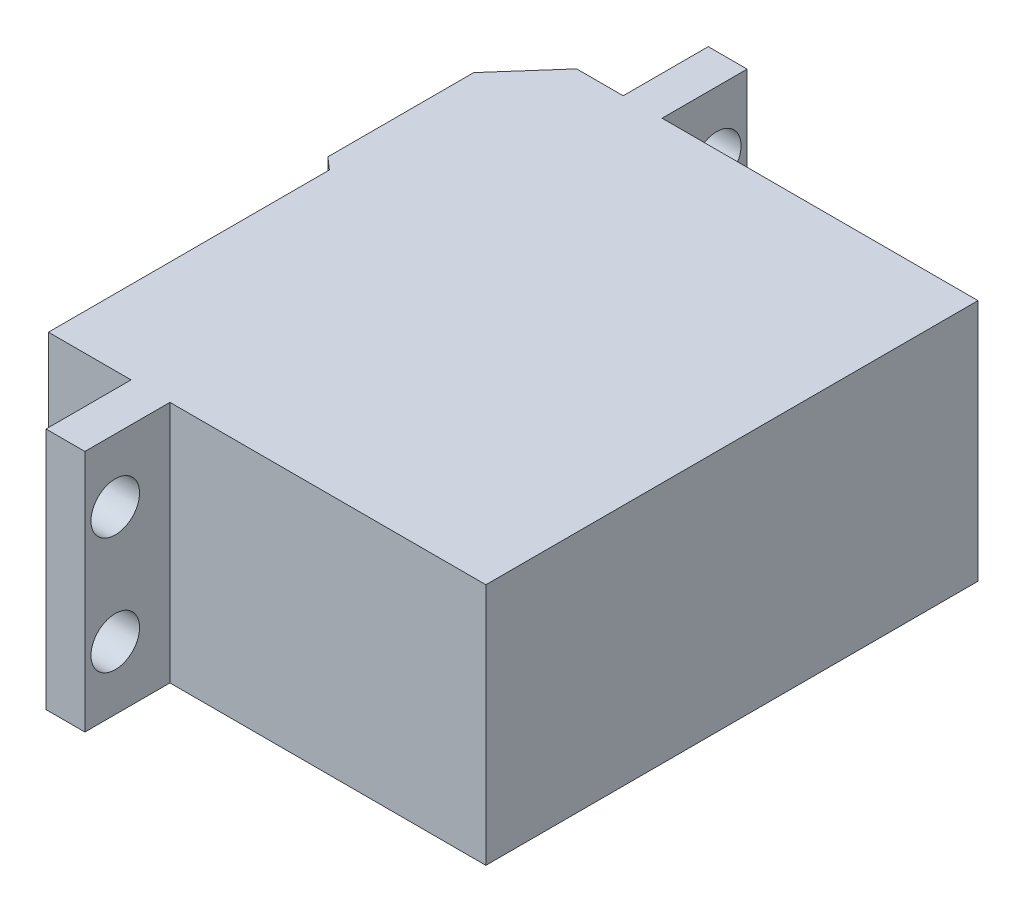
from build123d import *

# Parameters (mm, degrees)
BOSS_EXTRUDE1_DEPTH = 20
BOSS_EXTRUDE2_DEPTH = 4
SKETCH3_R           = 2
CUT_EXTRUDE1_DEPTH  = 30.2
SKETCH4_R           = 1.5
CUT_EXTRUDE2_DEPTH  = 2


with BuildPart() as part:
    # Sketch1 → Boss-Extrude1 (new body)
    with BuildSketch(Plane(origin=(0, 0, 0), x_dir=(1, 0, 0), z_dir=(0, 1, 0))):
        Polygon((0, 0), (0, 40.5), (-26, 40.5), (-26, 47.5), (-29.2, 47.5), (-29.2, 40.5), (-33.031373033, 40.5), (-37, 36), (-37, 24), (-36, 23.118082896), (-36, 0), (-29.2, 0), (-29.2, -7), (-26, -7), (-26, 0), align=None)
    extrude(amount=BOSS_EXTRUDE1_DEPTH)

    # Sketch2 → Boss-Extrude2 (add)
    with BuildSketch(Plane.ZY.offset(37)):
        Polygon((-33.464101615, 10), (-31.732050808, 7), (-28.267949192, 7), (-26.535898385, 10), (-28.267949192, 13), (-31.732050808, 13), align=None)
    extrude(amount=BOSS_EXTRUDE2_DEPTH)

    # Sketch3 → Cut-Extrude1 (cut, through all)
    with BuildSketch(Plane.ZY.offset(29.2)):
        with Locations((-45, 5.2)):
            Circle(SKETCH3_R)
        with Locations((-45, 14.8)):
            Circle(SKETCH3_R)
        with Locations((4.5, 14.8)):
            Circle(SKETCH3_R)
        with Locations((4.5, 5.2)):
            Circle(SKETCH3_R)
    extrude(amount=-CUT_EXTRUDE1_DEPTH, mode=Mode.SUBTRACT)

    # Sketch4 → Cut-Extrude2 (cut)
    with BuildSketch(Plane.ZY.offset(41)):
        with Locations((-30, 10)):
            Circle(SKETCH4_R)
    extrude(amount=-CUT_EXTRUDE2_DEPTH, mode=Mode.SUBTRACT)


solid = part.part
